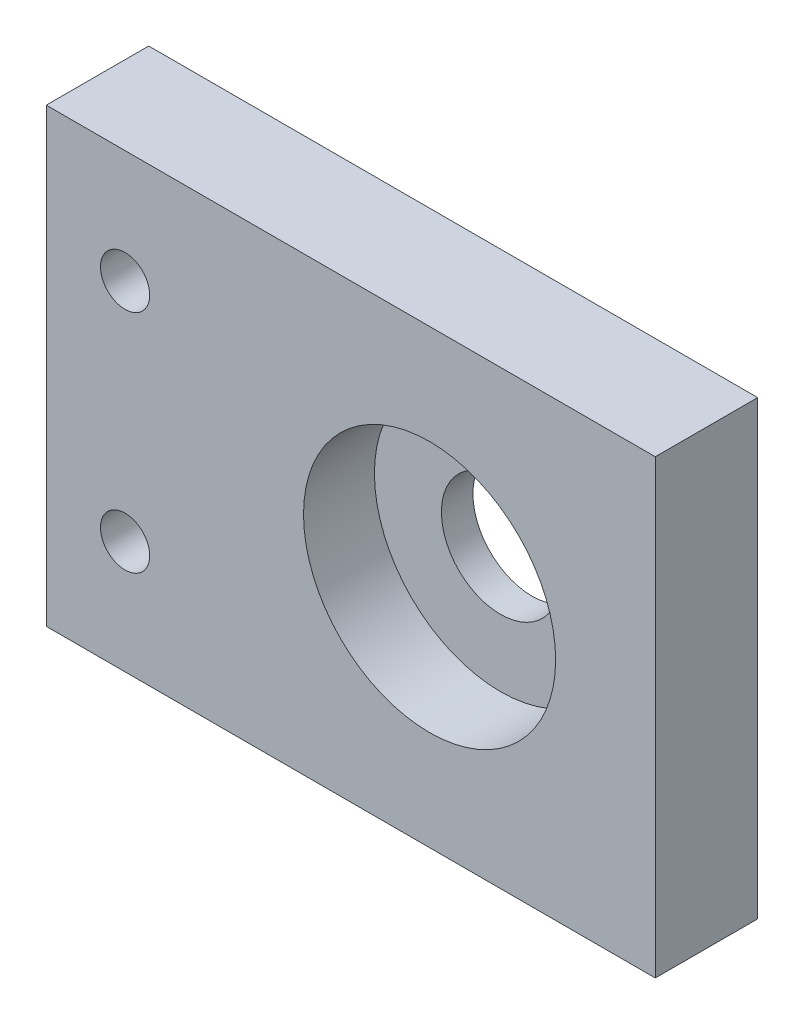
from build123d import *

# Parameters (mm, degrees)
SKETCH1_W                        = 77.3
SKETCH1_H                        = 57.3
BOSS_EXTRUDE1_DEPTH              = 13
TAP_DRILL_FOR_M6_HELICOIL1_D     = 6.25
TAP_DRILL_FOR_M6_HELICOIL1_DEPTH = 20
TAP_DRILL_FOR_M6_HELICOIL1_TIP   = 1.877689434
SKETCH2_R                        = 16
CUT_EXTRUDE1_DEPTH               = 9
SKETCH6_R                        = 7.5
CUT_EXTRUDE2_DEPTH               = 9


with BuildPart() as part:
    # Sketch1 → Boss-Extrude1 (new body)
    with BuildSketch(Plane.XY):
        Rectangle(SKETCH1_W, SKETCH1_H)
    extrude(amount=BOSS_EXTRUDE1_DEPTH)

    # Tap Drill for M6 Helicoil1
    with Locations(Plane(origin=(-28.65, 14.325, 13), x_dir=(1, 0, 0), z_dir=(0, 0, 1))):
        with Locations((0, 0), (0, -28.65)):
            Hole(TAP_DRILL_FOR_M6_HELICOIL1_D / 2, depth=TAP_DRILL_FOR_M6_HELICOIL1_DEPTH)
            with Locations((0, 0, -(TAP_DRILL_FOR_M6_HELICOIL1_DEPTH + TAP_DRILL_FOR_M6_HELICOIL1_TIP / 2))):  # 118° drill point
                Cone(0, TAP_DRILL_FOR_M6_HELICOIL1_D / 2, TAP_DRILL_FOR_M6_HELICOIL1_TIP, mode=Mode.SUBTRACT)

    # Sketch2 → Cut-Extrude1 (cut)
    with BuildSketch(Plane.XY.offset(13)):
        with Locations((10, 0)):
            Circle(SKETCH2_R)
    extrude(amount=-CUT_EXTRUDE1_DEPTH, mode=Mode.SUBTRACT)

    # Sketch6 → Cut-Extrude2 (cut)
    with BuildSketch(Plane.XY.offset(4)):
        with Locations((10, 0)):
            Circle(SKETCH6_R)
    extrude(amount=-CUT_EXTRUDE2_DEPTH, mode=Mode.SUBTRACT)


solid = part.part
